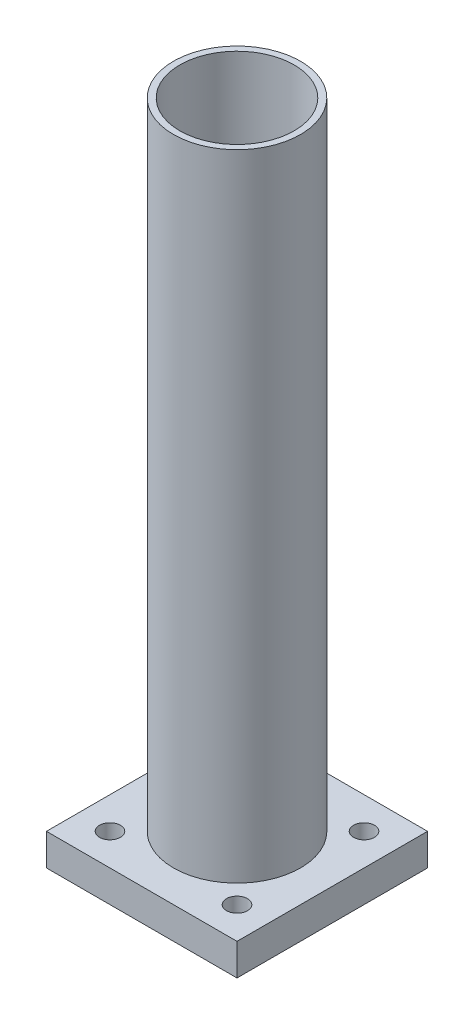
from build123d import *

# Parameters (mm, degrees)
SKETCH1_R                     = 20
SKETCH1_R_2                   = 18
BOSS_EXTRUDE1_DEPTH           = 200
SKETCH2_W                     = 60
SKETCH2_H                     = 60
BOSS_EXTRUDE2_DEPTH           = 10
SKETCH5_W                     = 3.3
SKETCH5_H                     = 10
M6_CLEARANCE_HOLE1_AT_2_COUNT = 2
M6_CLEARANCE_HOLE1_AT_2_PITCH = 40
M6_CLEARANCE_HOLE1_AT_3_COUNT = 2
M6_CLEARANCE_HOLE1_AT_3_PITCH = 56.568542495
M6_CLEARANCE_HOLE1_AT_4_COUNT = 2
M6_CLEARANCE_HOLE1_AT_4_PITCH = 40


with BuildPart() as part:
    # Sketch1 → Boss-Extrude1 (new body)
    with BuildSketch(Plane(origin=(0, 0, 0), x_dir=(1, 0, 0), z_dir=(0, 1, 0))):
        Circle(SKETCH1_R)
        Circle(SKETCH1_R_2, mode=Mode.SUBTRACT)
    extrude(amount=BOSS_EXTRUDE1_DEPTH)


with BuildPart() as body_2:
    # Sketch2 → Boss-Extrude2 (new body)
    with BuildSketch(Plane(origin=(0, 0, 0), x_dir=(1, 0, 0), z_dir=(0, 1, 0))):
        Rectangle(SKETCH2_W, SKETCH2_H)
    extrude(amount=-BOSS_EXTRUDE2_DEPTH)

    # Sketch5 → M6 Clearance Hole1 (revolve, cut)
    with BuildSketch(Plane(origin=(20, 0, -20), x_dir=(0, 0, 1), z_dir=(1, 0, 0))):
        with Locations((1.65, 5)):
            Rectangle(SKETCH5_W, SKETCH5_H)
    m6_clearance_hole1 = revolve(axis=Axis((20, 6.35, -20), (0, -1, 0)), mode=Mode.SUBTRACT)

    # M6 Clearance Hole1 at 2: M6 Clearance Hole1 ×2
    with Locations(*[(-i * M6_CLEARANCE_HOLE1_AT_2_PITCH, 0, 0) for i in range(1, M6_CLEARANCE_HOLE1_AT_2_COUNT)]):
        add(m6_clearance_hole1, mode=Mode.SUBTRACT)

    # M6 Clearance Hole1 at 3: M6 Clearance Hole1 ×2
    with Locations(*[Vector(-0.707106781, 0, 0.707106781) * (i * M6_CLEARANCE_HOLE1_AT_3_PITCH) for i in range(1, M6_CLEARANCE_HOLE1_AT_3_COUNT)]):
        add(m6_clearance_hole1, mode=Mode.SUBTRACT)

    # M6 Clearance Hole1 at 4: M6 Clearance Hole1 ×2
    with Locations(*[(0, 0, i * M6_CLEARANCE_HOLE1_AT_4_PITCH) for i in range(1, M6_CLEARANCE_HOLE1_AT_4_COUNT)]):
        add(m6_clearance_hole1, mode=Mode.SUBTRACT)


solid = Compound([part.part, body_2.part])
